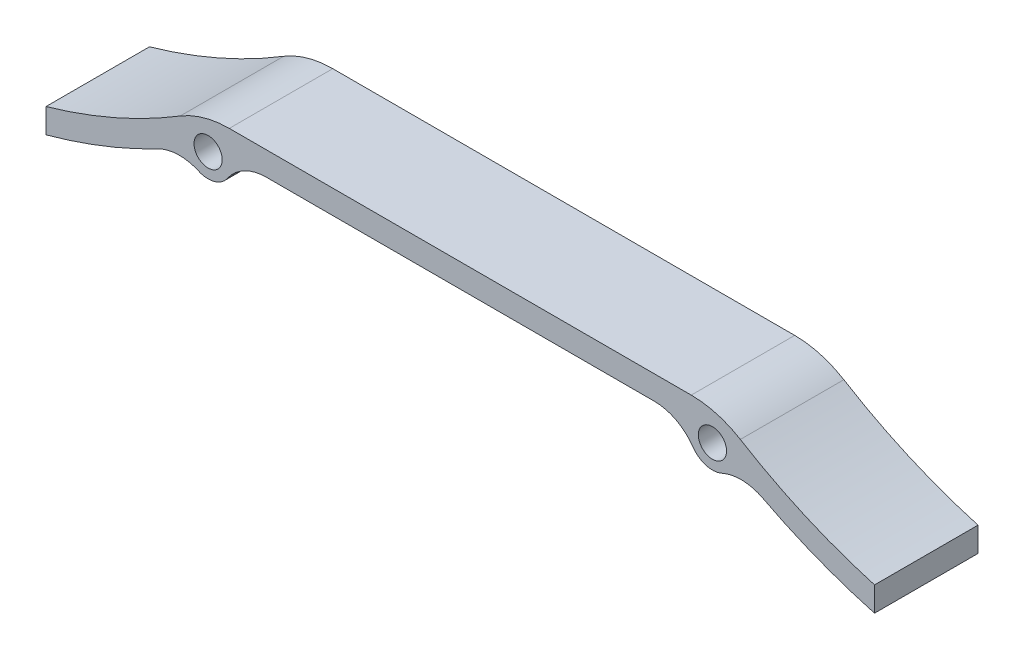
from build123d import *

# Parameters (mm, degrees)
ESBO_O1_R                = 3
RESSALTO_EXTRUS_O1_DEPTH = 22


with BuildPart() as part:
    # Esboço1 → Ressalto-extrusão1 (new body)
    with BuildSketch(Plane.XY):
        with BuildLine():
            Line((-49.119135606, 68), (49.119135606, 68))
            ThreePointArc((49.119135606, 68), (54.543435225, 67.250375935), (59.56111629, 65.057697365))
            ThreePointArc((59.56111629, 65.057697365), (73.40190502, 57.827992781), (88.094517748, 52.539969306))
            Line((88.094517748, 52.539969306), (88.094517748, 47.321908149))
            ThreePointArc((88.094517748, 47.321908149), (75.969961031, 51.336342949), (64.340736461, 56.616655277))
            ThreePointArc((64.340736461, 56.616655277), (60.029722653, 57.739663923), (55.658771962, 56.878979006))
            ThreePointArc((55.658771962, 56.878979006), (52.268274515, 56.633748331), (49.504565952, 58.613022442))
            ThreePointArc((49.504565952, 58.613022442), (45.919841237, 61.796967806), (41.265094556, 62.946355775))
            Line((41.265094556, 62.946355775), (-41.265094556, 62.946355775))
            ThreePointArc((-41.265094556, 62.946355775), (-45.919841237, 61.796967806), (-49.504565952, 58.613022442))
            ThreePointArc((-49.504565952, 58.613022442), (-52.268274515, 56.633748331), (-55.658771962, 56.878979006))
            ThreePointArc((-55.658771962, 56.878979006), (-60.029722653, 57.739663923), (-64.340736461, 56.616655277))
            ThreePointArc((-64.340736461, 56.616655277), (-75.969961031, 51.336342949), (-88.094517748, 47.321908149))
            Line((-88.094517748, 47.321908149), (-88.094517748, 52.539969306))
            ThreePointArc((-88.094517748, 52.539969306), (-73.40190502, 57.827992781), (-59.56111629, 65.057697365))
            ThreePointArc((-59.56111629, 65.057697365), (-54.543435225, 67.250375935), (-49.119135606, 68))
        make_face()
        with Locations((-53.62430165, 61.446355775)):
            Circle(ESBO_O1_R, mode=Mode.SUBTRACT)
        with Locations((53.62430165, 61.446355775)):
            Circle(ESBO_O1_R, mode=Mode.SUBTRACT)
    extrude(amount=RESSALTO_EXTRUS_O1_DEPTH)


solid = part.part
